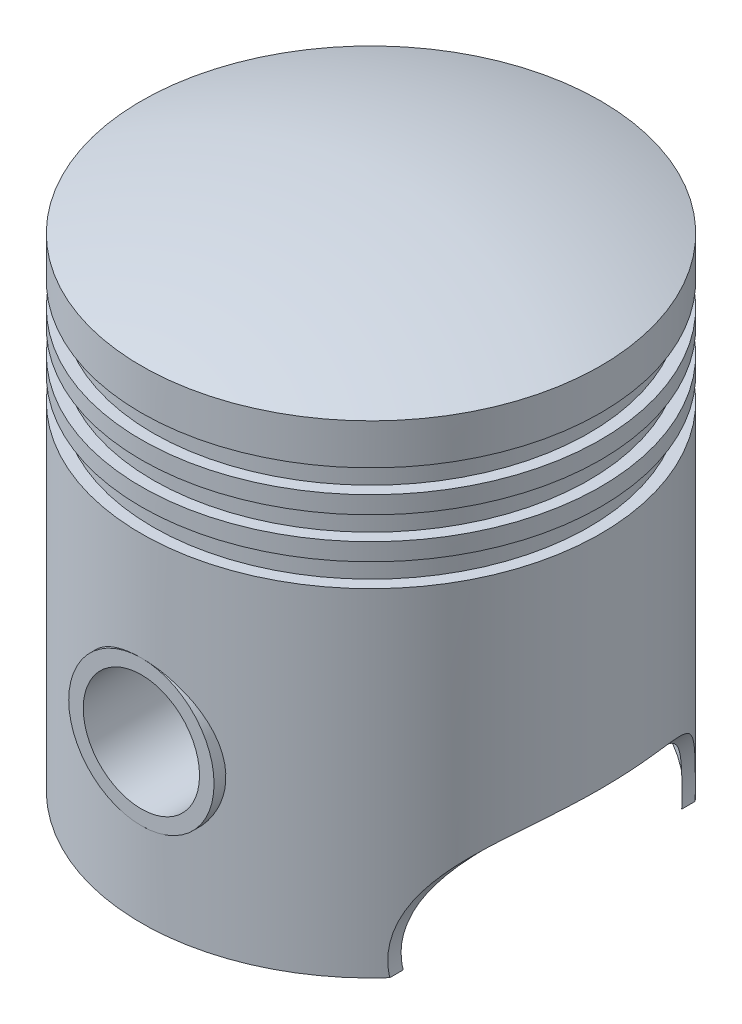
from build123d import *

# Parameters (mm, degrees)
BOSS_EXTRUDE1_START = 10
SKETCH3_R           = 12.5
BOSS_EXTRUDE1_DEPTH = 29.5
SKETCH4_R           = 10
CUT_EXTRUDE1_DEPTH  = 29.5
SKETCH5_W           = 4
SKETCH5_H           = 4
CUT_EXTRUDE2_DEPTH  = 40.5000001


with BuildPart() as part:
    # Sketch1 → Revolve1 (revolve)
    with BuildSketch(Plane(origin=(0, 0, 0), x_dir=(0, 0, -1), z_dir=(1, 0, 0))):
        with BuildLine():
            Line((0, 0), (0, 90))
            ThreePointArc((0, 90), (20.057729184, 88.236471821), (39.5, 83))
            Line((39.5, 83), (39.5, 0))
            Line((39.5, 0), (0, 0))
        make_face()
    revolve(axis=Axis((0, 0, 0), (0, 1, 0)))

    # Sketch2 → Cut-Revolve1 (revolve, cut)
    with BuildSketch(Plane(origin=(0, 0, 0), x_dir=(0, 0, -1), z_dir=(1, 0, 0))):
        with BuildLine():
            Line((0, 0), (0, 85))
            ThreePointArc((0, 85), (26.870057685, 73.870057685), (38, 47))
            Line((38, 47), (38, 0))
            Line((38, 0), (0, 0))
        make_face()
    revolve(axis=Axis((0, 0, 0), (0, 1, 0)), mode=Mode.SUBTRACT)

    # Sketch3 → Boss-Extrude1 (add, through all)
    with BuildSketch(Plane.XY.offset(BOSS_EXTRUDE1_START)):
        with Locations((0, 27)):
            Circle(SKETCH3_R)
    boss_extrude1 = extrude(amount=BOSS_EXTRUDE1_DEPTH)

    # Sketch4 → Cut-Extrude1 (cut)
    with BuildSketch(Plane.XY.offset(39.5)):
        with Locations((0, 27)):
            Circle(SKETCH4_R)
    cut_extrude1 = extrude(amount=-CUT_EXTRUDE1_DEPTH, mode=Mode.SUBTRACT)

    # Mirror1: Boss-Extrude1, Cut-Extrude1 across plane
    add(boss_extrude1.mirror(Plane(origin=(0, 0, 0), x_dir=(0, 0, 1), z_dir=(1, 0, 0))))
    add(cut_extrude1.mirror(Plane(origin=(0, 0, 0), x_dir=(0, 0, 1), z_dir=(1, 0, 0))), mode=Mode.SUBTRACT)

    # Mirror2: Boss-Extrude1, Cut-Extrude1 across plane
    add(boss_extrude1.mirror(Plane.XY))
    add(cut_extrude1.mirror(Plane.XY), mode=Mode.SUBTRACT)

    # Sketch5 → Cut-Revolve5 (revolve, cut)
    with BuildSketch(Plane.XY):
        with Locations((-39.5, 74)):
            Rectangle(SKETCH5_W, SKETCH5_H)
        with Locations((-39.5, 67)):
            Rectangle(SKETCH5_W, SKETCH5_H)
        with Locations((-39.5, 60)):
            Rectangle(SKETCH5_W, SKETCH5_H)
    revolve(axis=Axis((0, 0, 0), (0, -1, 0)), mode=Mode.SUBTRACT)

    # Sketch6 → Cut-Extrude2 (cut, symmetric)
    with BuildSketch(Plane.XY):
        with BuildLine():
            Line((39.5, 0), (29.5, 0))
            ThreePointArc((29.5, 0), (31.443853154, 11.528073423), (39.5, 20))
            Line((39.5, 20), (39.5, 0))
        make_face()
    cut_extrude2 = extrude(amount=CUT_EXTRUDE2_DEPTH, both=True, mode=Mode.SUBTRACT)

    # Mirror3: Cut-Extrude2 across plane
    add(cut_extrude2.mirror(Plane(origin=(0, 0, 0), x_dir=(0, 0, 1), z_dir=(1, 0, 0))), mode=Mode.SUBTRACT)


solid = part.part
